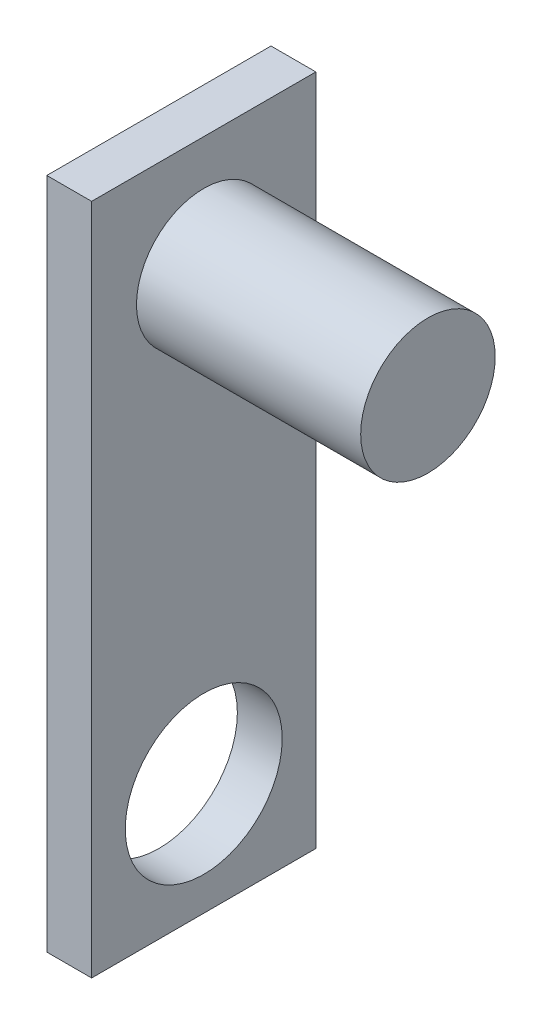
from build123d import *

# Parameters (mm, degrees)
SKETCH1_W           = 10
SKETCH1_H           = 30
BOSS_EXTRUDE1_DEPTH = 2
SKETCH2_R           = 3.5
CUT_EXTRUDE1_DEPTH  = 2
SKETCH3_R           = 3
BOSS_EXTRUDE2_DEPTH = 10


with BuildPart() as part:
    # Sketch1 → Boss-Extrude1 (new body)
    with BuildSketch(Plane(origin=(0, 0, 0), x_dir=(0, 0, -1), z_dir=(1, 0, 0))):
        Rectangle(SKETCH1_W, SKETCH1_H)
    extrude(amount=BOSS_EXTRUDE1_DEPTH)

    # Sketch2 → Cut-Extrude1 (cut)
    with BuildSketch(Plane(origin=(2, 0, 0), x_dir=(0, 0, -1), z_dir=(1, 0, 0))):
        with Locations((0, -10)):
            Circle(SKETCH2_R)
    extrude(amount=-CUT_EXTRUDE1_DEPTH, mode=Mode.SUBTRACT)

    # Sketch3 → Boss-Extrude2 (add)
    with BuildSketch(Plane(origin=(2, 0, 0), x_dir=(0, 0, -1), z_dir=(1, 0, 0))):
        with Locations((0, 10)):
            Circle(SKETCH3_R)
    extrude(amount=BOSS_EXTRUDE2_DEPTH)


solid = part.part
